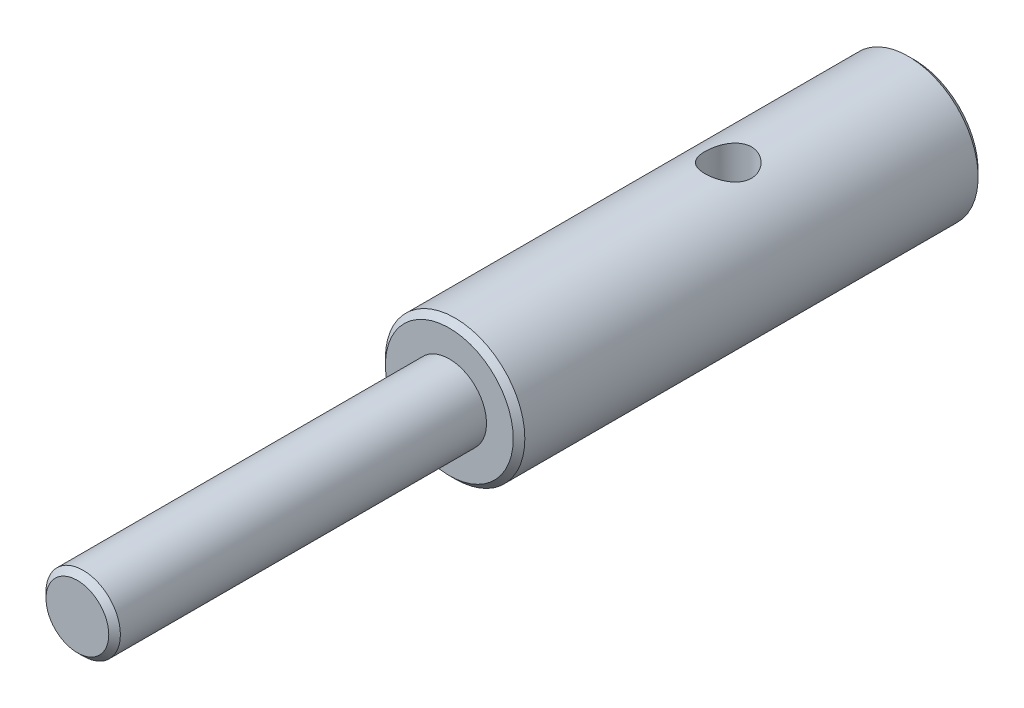
from build123d import *

# Parameters (mm, degrees)
SKIZZE2_R                       = 1
SCHNITT_LINEAR_AUSTRAGEN1_DEPTH = 4
FASE1_SIZE                      = 0.25


with BuildPart() as part:
    # Skizze1 → Rotation1 (revolve)
    with BuildSketch(Plane(origin=(0, 0, 0), x_dir=(0, 0, -1), z_dir=(1, 0, 0))):
        Polygon((0, 1), (10, 1), (10, 3), (-10, 3), (-10, 1.6), (-26, 1.6), (-26, 0), (0, 0), align=None)
    revolve(axis=Axis((0, 0, 0), (0, 0, 1)))

    # Skizze2 → Schnitt-Linear austragen1 (cut, through all)
    with BuildSketch(Plane(origin=(0, 0, 0), x_dir=(1, 0, 0), z_dir=(0, 1, 0))):
        with Locations((0, 2)):
            Circle(SKIZZE2_R)
    extrude(amount=SCHNITT_LINEAR_AUSTRAGEN1_DEPTH, mode=Mode.SUBTRACT)

    # Fase1
    fase1_edges = [part.edges().sort_by_distance(p)[0] for p in [
        (0, -3, -10),
        (0, -3, 10),
        (0, -1.6, 26),
    ]]
    chamfer(fase1_edges, length=FASE1_SIZE)


solid = part.part
